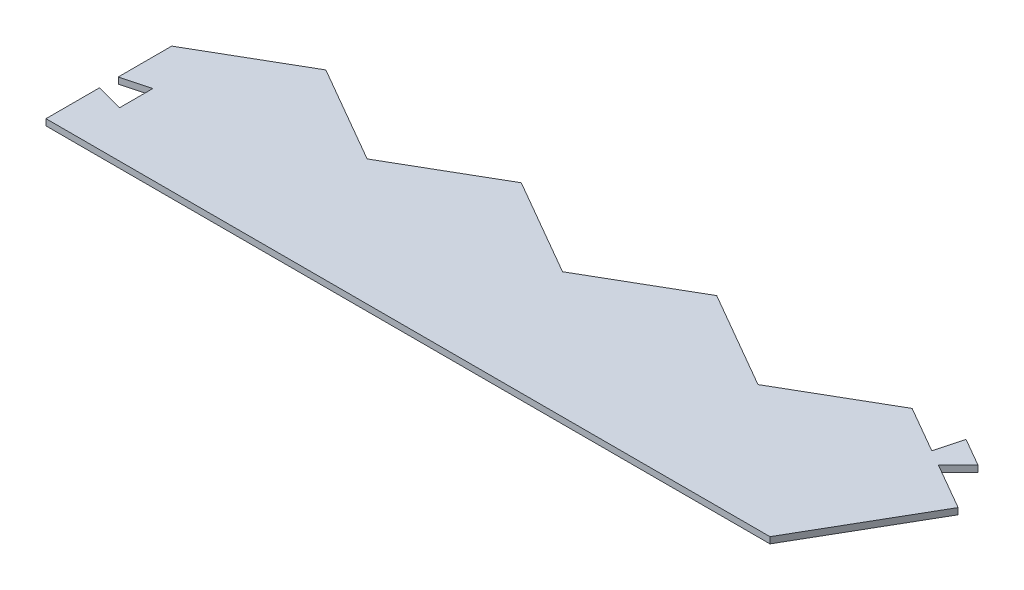
from build123d import *

# Parameters (mm, degrees)
BOSS_EXTRUDE1_DEPTH = 2.54


with BuildPart() as part:
    # Sketch1 → Boss-Extrude1 (new body)
    with BuildSketch(Plane(origin=(0, 0, 0), x_dir=(1, 0, 0), z_dir=(0, 1, 0))):
        Polygon((0, 0), (0, 21.59), (11.040532194, 18.631698314), (11.040532194, 32.168301686), (0, 29.21), (0, 50.8), (39.484696235, 73.5965), (78.969392469, 50.8), (118.454088704, 73.5965), (157.938784939, 50.8), (197.423481174, 73.5965), (236.908177408, 50.8), (276.392873643, 73.5965), (295.200347337, 62.738), (298.125779004, 73.655859615), (309.571918409, 67.047427948), (301.579490461, 59.055), (320.386964155, 48.1965), (292.560701906, 0), (234.928443335, 0), (156.618962224, 0), (78.969392469, 0), align=None)
    extrude(amount=BOSS_EXTRUDE1_DEPTH)


solid = part.part
